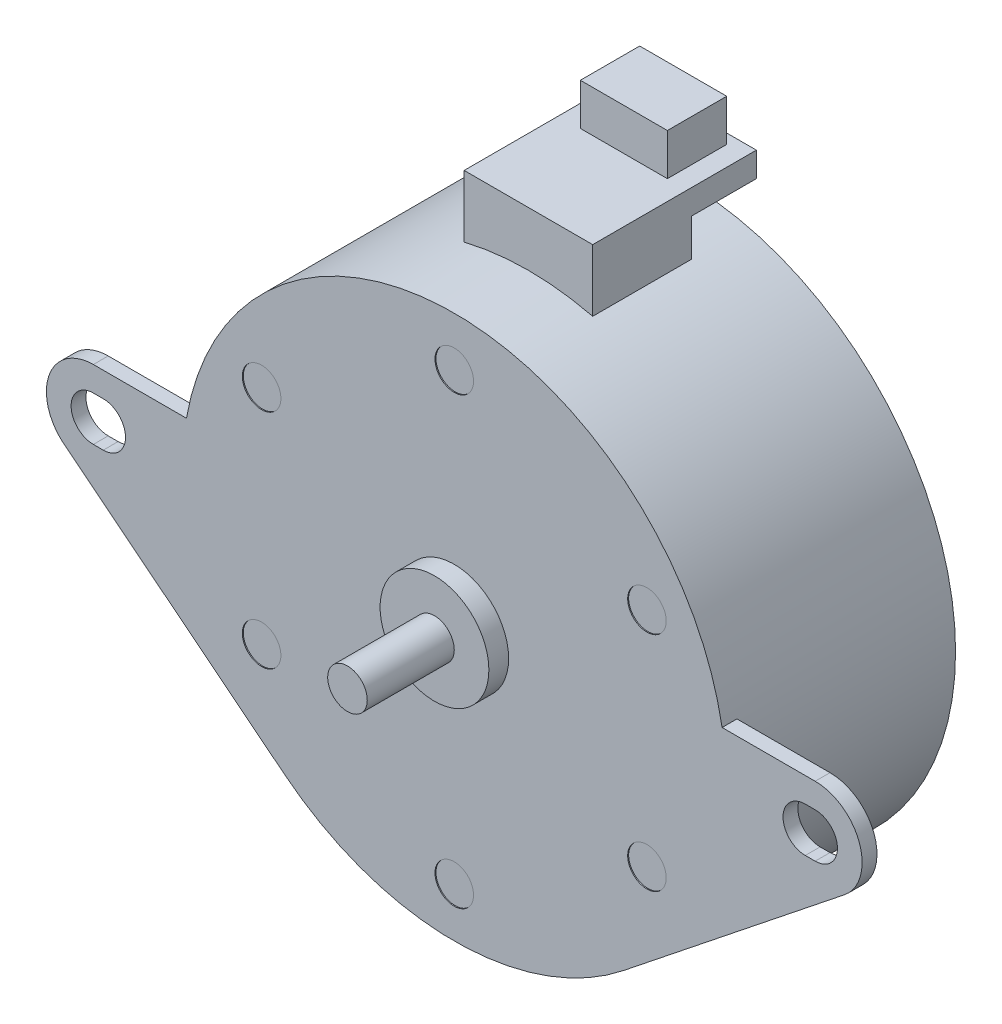
from build123d import *

# Parameters (mm, degrees)
SKETCH1_W                    = 27.5
SKETCH1_H                    = 23.2
BOSS_EXTRUDE1_REACH          = 62.5
SKETCH2_W                    = 13
SKETCH2_H                    = 10
BOSS_EXTRUDE2_DEPTH          = 16.55326241
BOSS_EXTRUDE3_DEPTH          = 1.5
BOSS_EXTRUDE4_DEPTH          = 1.5
CUT_EXTRUDE1_DEPTH           = 25.05326251
CUT_EXTRUDE2_DEPTH           = 2.5
SKETCH8_R                    = 5.5
BOSS_EXTRUDE5_DEPTH          = 2
SKETCH9_R                    = 2
BOSS_EXTRUDE6_DEPTH          = 8.8
SKETCH10_W                   = 8.8
SKETCH10_H                   = 6
BOSS_EXTRUDE7_DEPTH          = 4.22
CUT_EXTRUDE3_START           = -1
SKETCH11_W                   = 6.8
SKETCH11_H                   = 2.22
CUT_EXTRUDE3_DEPTH           = 5
SKETCH12_R                   = 19.15
BOSS_EXTRUDE8_DEPTH          = 1.5
BOSS_EXTRUDE8_TAPER          = 45
F_7_0_7_DIAMETER_HOLE1_D     = 7
F_7_0_7_DIAMETER_HOLE1_DEPTH = 1.5
SKETCH15_W                   = 1.95
SKETCH15_H                   = 0.1
SKETCH16_W                   = 1.95
SKETCH16_H                   = 0.1
SKETCH17_W                   = 1.95
SKETCH17_H                   = 0.1
SKETCH18_W                   = 1.95
SKETCH18_H                   = 0.1
SKETCH19_W                   = 1.95
SKETCH19_H                   = 0.1
SKETCH20_W                   = 1.95
SKETCH20_H                   = 0.1
SKETCH21_W                   = 2
SKETCH21_H                   = 7
SKETCH22_W                   = 1.95
SKETCH22_H                   = 0.9
SKETCH23_W                   = 1.95
SKETCH23_H                   = 0.9
SKETCH24_W                   = 1.95
SKETCH24_H                   = 0.9
SKETCH25_W                   = 1.95
SKETCH25_H                   = 0.9
SKETCH26_W                   = 1.95
SKETCH26_H                   = 0.9
SKETCH27_W                   = 1.95
SKETCH27_H                   = 0.9


with BuildPart() as part:
    # Sketch1 → Revolve1 (revolve)
    with BuildSketch(Plane.XZ.offset(-27.5)):
        with Locations((41.25, 11.6)):
            Rectangle(SKETCH1_W, SKETCH1_H)
    revolve(axis=Axis((27.5, 27.5, 23.2), (0, 0, -1)))

    # Sketch2 → Boss-Extrude1 (add, up to next)
    with BuildSketch(Plane(origin=(0, 60.5, 0), x_dir=(1, 0, 0), z_dir=(0, 1, 0)), mode=Mode.PRIVATE) as boss_extrude1_sk1:
        with Locations((27.5, -10.7)):
            Rectangle(SKETCH2_W, SKETCH2_H)
    boss_extrude1_tool1 = extrude(boss_extrude1_sk1.sketch, amount=-BOSS_EXTRUDE1_REACH, mode=Mode.PRIVATE) - part.part
    add(boss_extrude1_tool1.solids().sort_by_distance((27.5, 60.5, 10.7))[0])

    # Sketch3 → Boss-Extrude2 (add)
    with BuildSketch(Plane.XY.offset(15.7)):
        with BuildLine():
            Line((34, 60.5), (34, 58))
            add(Edge.make_bspline(
                [(21, 58), (34, 58)],
                knots=[0, 0, 1, 1], degree=1))
            Line((21, 58), (21, 60.5))
            Line((21, 60.5), (34, 60.5))
        make_face()
    extrude(amount=-BOSS_EXTRUDE2_DEPTH)

    # Sketch4 → Boss-Extrude3 (add)
    with BuildSketch(Plane.XY.offset(23.2)):
        with BuildLine():
            Line((64, 32.25), (54.586666462, 32.25))
            ThreePointArc((54.586666462, 32.25), (53.216477037, 17.757679496), (44.640410959, 5.995202578))
            Line((44.640410959, 5.995202578), (66.960616438, 23.785534991))
            ThreePointArc((66.960616438, 23.785534991), (68.483648559, 29.068246028), (64, 32.25))
        make_face()
    extrude(amount=-BOSS_EXTRUDE3_DEPTH)

    # Sketch5 → Boss-Extrude4 (add)
    with BuildSketch(Plane.XY.offset(23.2)):
        with BuildLine():
            Line((-11.960616438, 23.785534991), (10.359589041, 5.995202578))
            ThreePointArc((10.359589041, 5.995202578), (1.783522963, 17.757679496), (0.413333538, 32.25))
            Line((0.413333538, 32.25), (-9, 32.25))
            ThreePointArc((-9, 32.25), (-13.483648559, 29.068246028), (-11.960616438, 23.785534991))
        make_face()
    extrude(amount=-BOSS_EXTRUDE4_DEPTH)

    # Sketch6 → Cut-Extrude1 (cut, through all)
    with BuildSketch(Plane.XY.offset(23.2)):
        with BuildLine():
            Line((63, 25.25), (64, 25.25))
            ThreePointArc((64, 25.25), (66.25, 27.5), (64, 29.75))
            Line((64, 29.75), (63, 29.75))
            ThreePointArc((63, 29.75), (60.75, 27.5), (63, 25.25))
        make_face()
    extrude(amount=-CUT_EXTRUDE1_DEPTH, mode=Mode.SUBTRACT)

    # Sketch7 → Cut-Extrude2 (cut, through all)
    with BuildSketch(Plane(origin=(0, 0, 21.7), x_dir=(-1, 0, 0), z_dir=(0, 0, -1))):
        with BuildLine():
            Line((8, 25.25), (9, 25.25))
            ThreePointArc((9, 25.25), (11.25, 27.5), (9, 29.75))
            Line((9, 29.75), (8, 29.75))
            ThreePointArc((8, 29.75), (5.75, 27.5), (8, 25.25))
        make_face()
    extrude(amount=-CUT_EXTRUDE2_DEPTH, mode=Mode.SUBTRACT)

    # Sketch8 → Boss-Extrude5 (add)
    with BuildSketch(Plane.XY.offset(23.2)):
        with Locations((27.5, 27.5)):
            Circle(SKETCH8_R)
    extrude(amount=BOSS_EXTRUDE5_DEPTH)

    # Sketch9 → Boss-Extrude6 (add)
    with BuildSketch(Plane.XY.offset(25.2)):
        with Locations((27.5, 27.5)):
            Circle(SKETCH9_R)
    extrude(amount=BOSS_EXTRUDE6_DEPTH)

    # Sketch10 → Boss-Extrude7 (add)
    with BuildSketch(Plane(origin=(0, 60.5, 0), x_dir=(-1, 0, 0), z_dir=(0, 1, 0))):
        with Locations((-27.6, 3.14673759)):
            Rectangle(SKETCH10_W, SKETCH10_H)
    extrude(amount=BOSS_EXTRUDE7_DEPTH)

    # Sketch11 → Cut-Extrude3 (cut)
    with BuildSketch(Plane.XY.offset(6.14673759).offset(CUT_EXTRUDE3_START)):
        with Locations((27.6, 62.61)):
            Rectangle(SKETCH11_W, SKETCH11_H)
    extrude(amount=-CUT_EXTRUDE3_DEPTH, mode=Mode.SUBTRACT)

    # Sketch12 → Boss-Extrude8 (add)
    with BuildSketch(Plane(origin=(0, 0, 0), x_dir=(-1, 0, 0), z_dir=(0, 0, -1))):
        with Locations((-27.5, 27.5)):
            Circle(SKETCH12_R)
    extrude(amount=BOSS_EXTRUDE8_DEPTH, taper=BOSS_EXTRUDE8_TAPER)

    # Ø7.0 (7) Diameter Hole1
    with Locations(Plane(origin=(0, 0, -1.5), x_dir=(-1, 0, 0), z_dir=(0, 0, -1))):
        with Locations((-27.5, 27.5)):
            Hole(F_7_0_7_DIAMETER_HOLE1_D / 2, depth=F_7_0_7_DIAMETER_HOLE1_DEPTH)

    # Sketch15 → Cut-Revolve1 (revolve, cut)
    with BuildSketch(Plane(origin=(0, 16.25, 0), x_dir=(1, 0, 0), z_dir=(0, 1, 0))):
        with Locations((8.989428415, -23.15)):
            Rectangle(SKETCH15_W, SKETCH15_H)
    revolve(axis=Axis((8.014428415, 16.25, 23.1), (0, 0, 1)), mode=Mode.SUBTRACT)

    # Sketch16 → Cut-Revolve2 (revolve, cut)
    with BuildSketch(Plane(origin=(0, 5, 0), x_dir=(1, 0, 0), z_dir=(0, 1, 0))):
        with Locations((28.475, -23.15)):
            Rectangle(SKETCH16_W, SKETCH16_H)
    revolve(axis=Axis((27.5, 5, 23.1), (0, 0, 1)), mode=Mode.SUBTRACT)

    # Sketch17 → Cut-Revolve3 (revolve, cut)
    with BuildSketch(Plane(origin=(0, 16.25, 0), x_dir=(1, 0, 0), z_dir=(0, 1, 0))):
        with Locations((47.960571585, -23.15)):
            Rectangle(SKETCH17_W, SKETCH17_H)
    revolve(axis=Axis((46.985571585, 16.25, 23.1), (0, 0, 1)), mode=Mode.SUBTRACT)

    # Sketch18 → Cut-Revolve4 (revolve, cut)
    with BuildSketch(Plane(origin=(0, 38.75, 0), x_dir=(1, 0, 0), z_dir=(0, 1, 0))):
        with Locations((47.960571585, -23.15)):
            Rectangle(SKETCH18_W, SKETCH18_H)
    revolve(axis=Axis((46.985571585, 38.75, 23.1), (0, 0, 1)), mode=Mode.SUBTRACT)

    # Sketch19 → Cut-Revolve5 (revolve, cut)
    with BuildSketch(Plane(origin=(0, 50, 0), x_dir=(1, 0, 0), z_dir=(0, 1, 0))):
        with Locations((28.475, -23.15)):
            Rectangle(SKETCH19_W, SKETCH19_H)
    revolve(axis=Axis((27.5, 50, 23.1), (0, 0, 1)), mode=Mode.SUBTRACT)

    # Sketch20 → Cut-Revolve6 (revolve, cut)
    with BuildSketch(Plane(origin=(0, 38.75, 0), x_dir=(1, 0, 0), z_dir=(0, 1, 0))):
        with Locations((8.989428415, -23.15)):
            Rectangle(SKETCH20_W, SKETCH20_H)
    revolve(axis=Axis((8.014428415, 38.75, 23.1), (0, 0, 1)), mode=Mode.SUBTRACT)

    # Sketch21 → Revolve2 (revolve)
    with BuildSketch(Plane(origin=(0, 27.5, 0), x_dir=(1, 0, 0), z_dir=(0, 1, 0))):
        with Locations((28.5, 3.5)):
            Rectangle(SKETCH21_W, SKETCH21_H)
    revolve(axis=Axis((27.5, 27.5, -7), (0, 0, 1)))

    # Sketch22 → Revolve3 (revolve)
    with BuildSketch(Plane(origin=(0, 16.25, 0), x_dir=(1, 0, 0), z_dir=(0, 1, 0))):
        with Locations((47.960571585, 0.45)):
            Rectangle(SKETCH22_W, SKETCH22_H)
    revolve(axis=Axis((46.985571585, 16.25, -0.9), (0, 0, 1)))

    # Sketch23 → Revolve4 (revolve)
    with BuildSketch(Plane(origin=(0, 5, 0), x_dir=(1, 0, 0), z_dir=(0, 1, 0))):
        with Locations((28.475, 0.45)):
            Rectangle(SKETCH23_W, SKETCH23_H)
    revolve(axis=Axis((27.5, 5, -0.9), (0, 0, 1)))

    # Sketch24 → Revolve5 (revolve)
    with BuildSketch(Plane(origin=(0, 16.25, 0), x_dir=(1, 0, 0), z_dir=(0, 1, 0))):
        with Locations((8.989428415, 0.45)):
            Rectangle(SKETCH24_W, SKETCH24_H)
    revolve(axis=Axis((8.014428415, 16.25, -0.9), (0, 0, 1)))

    # Sketch25 → Revolve6 (revolve)
    with BuildSketch(Plane(origin=(0, 38.75, 0), x_dir=(1, 0, 0), z_dir=(0, 1, 0))):
        with Locations((8.989428415, 0.45)):
            Rectangle(SKETCH25_W, SKETCH25_H)
    revolve(axis=Axis((8.014428415, 38.75, -0.9), (0, 0, 1)))

    # Sketch26 → Revolve7 (revolve)
    with BuildSketch(Plane(origin=(0, 50, 0), x_dir=(1, 0, 0), z_dir=(0, 1, 0))):
        with Locations((28.475, 0.45)):
            Rectangle(SKETCH26_W, SKETCH26_H)
    revolve(axis=Axis((27.5, 50, -0.9), (0, 0, 1)))

    # Sketch27 → Revolve8 (revolve)
    with BuildSketch(Plane(origin=(0, 38.75, 0), x_dir=(1, 0, 0), z_dir=(0, 1, 0))):
        with Locations((47.960571585, 0.45)):
            Rectangle(SKETCH27_W, SKETCH27_H)
    revolve(axis=Axis((46.985571585, 38.75, -0.9), (0, 0, 1)))


solid = part.part
